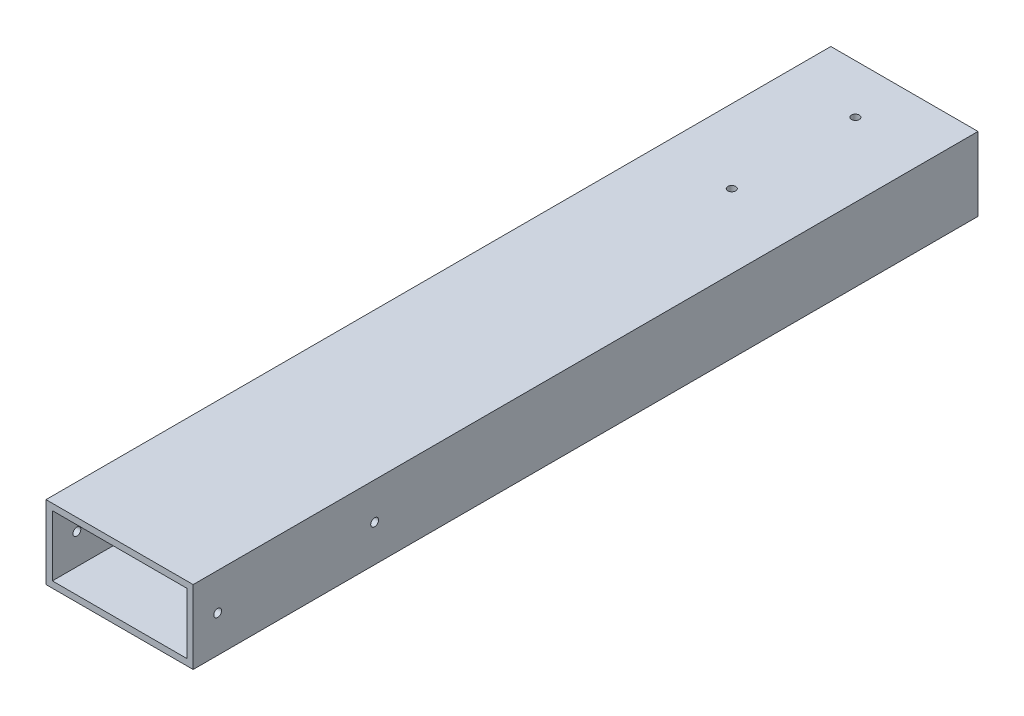
from build123d import *

# Parameters (mm, degrees)
SKETCH2_W           = 38.1
SKETCH2_H           = 19.05
SKETCH2_W_2         = 34.798
SKETCH2_H_2         = 15.748
BOSS_EXTRUDE1_DEPTH = 203.2
SKETCH3_R           = 1.016
CUT_EXTRUDE1_DEPTH  = 39.1
CUT_EXTRUDE2_REACH  = 21.05
SKETCH6_R           = 1.016


with BuildPart() as part:
    # Sketch2 → Boss-Extrude1 (new body)
    with BuildSketch(Plane.XY):
        Rectangle(SKETCH2_W, SKETCH2_H)
        Rectangle(SKETCH2_W_2, SKETCH2_H_2, mode=Mode.SUBTRACT)
    extrude(amount=BOSS_EXTRUDE1_DEPTH)

    # Sketch3 → Cut-Extrude1 (cut, through all)
    with BuildSketch(Plane(origin=(19.05, 0, 0), x_dir=(0, 0, -1), z_dir=(1, 0, 0))):
        with Locations((-196.85, 0)):
            Circle(SKETCH3_R)
        with Locations((-156.21, 0)):
            Circle(SKETCH3_R)
    extrude(amount=-CUT_EXTRUDE1_DEPTH, mode=Mode.SUBTRACT)

    # Sketch6 → Cut-Extrude2 (cut, up to next)
    with BuildSketch(Plane(origin=(0, 9.525, 0), x_dir=(1, 0, 0), z_dir=(0, 1, 0)), mode=Mode.PRIVATE) as cut_extrude2_sk1:
        with Locations((0, -12.7)):
            Circle(SKETCH6_R)
    cut_extrude2_tool1 = extrude(cut_extrude2_sk1.sketch, amount=-CUT_EXTRUDE2_REACH, mode=Mode.PRIVATE) & part.part
    add(cut_extrude2_tool1.solids().sort_by_distance((0, 9.525, 12.7))[0], mode=Mode.SUBTRACT)
    # Sketch6 → Cut-Extrude2 (cut, up to next)
    with BuildSketch(Plane(origin=(0, 9.525, 0), x_dir=(1, 0, 0), z_dir=(0, 1, 0)), mode=Mode.PRIVATE) as cut_extrude2_sk2:
        with Locations((0, -44.704)):
            Circle(SKETCH6_R)
    cut_extrude2_tool2 = extrude(cut_extrude2_sk2.sketch, amount=-CUT_EXTRUDE2_REACH, mode=Mode.PRIVATE) & part.part
    add(cut_extrude2_tool2.solids().sort_by_distance((0, 9.525, 44.704))[0], mode=Mode.SUBTRACT)


solid = part.part
